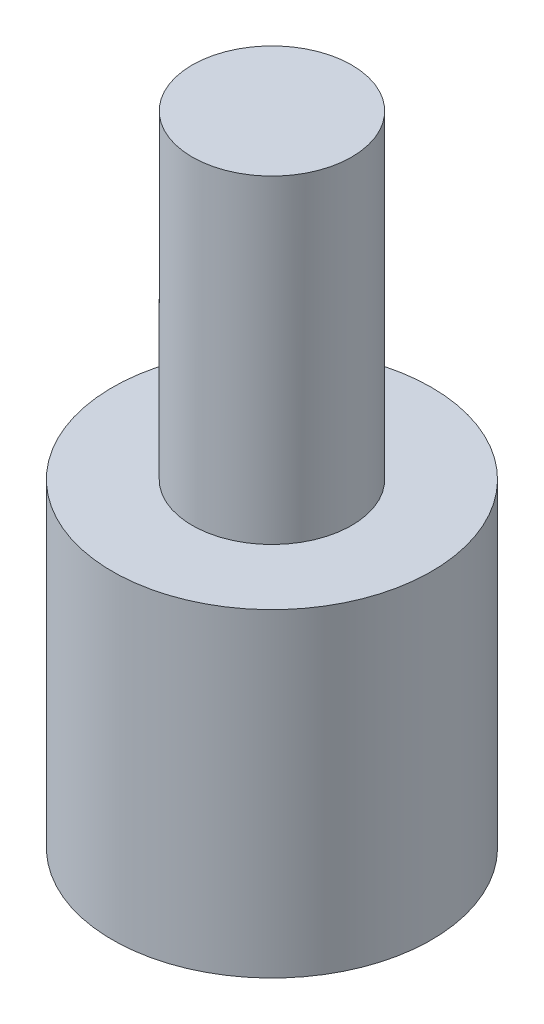
from build123d import *

# Parameters (mm, degrees)
SKIZZE1_R                       = 2.5
AUFSATZ_LINEAR_AUSTRAGEN1_DEPTH = 10
SKIZZE2_R                       = 5
AUFSATZ_LINEAR_AUSTRAGEN2_DEPTH = 10


with BuildPart() as part:
    # Skizze1 → Aufsatz-Linear austragen1 (new body)
    with BuildSketch(Plane(origin=(0, 0, 0), x_dir=(1, 0, 0), z_dir=(0, 1, 0))):
        with Locations(Location((0, 0, 0), (0, 0, 270))):  # turned: the seam where the file's is
            Circle(SKIZZE1_R)
    extrude(amount=AUFSATZ_LINEAR_AUSTRAGEN1_DEPTH)

    # Skizze2 → Aufsatz-Linear austragen2 (add)
    with BuildSketch(Plane.XZ):
        with Locations(Location((0, 0, 0), (0, 0, 270))):  # turned: the seam where the file's is
            Circle(SKIZZE2_R)
    extrude(amount=AUFSATZ_LINEAR_AUSTRAGEN2_DEPTH)


solid = part.part
